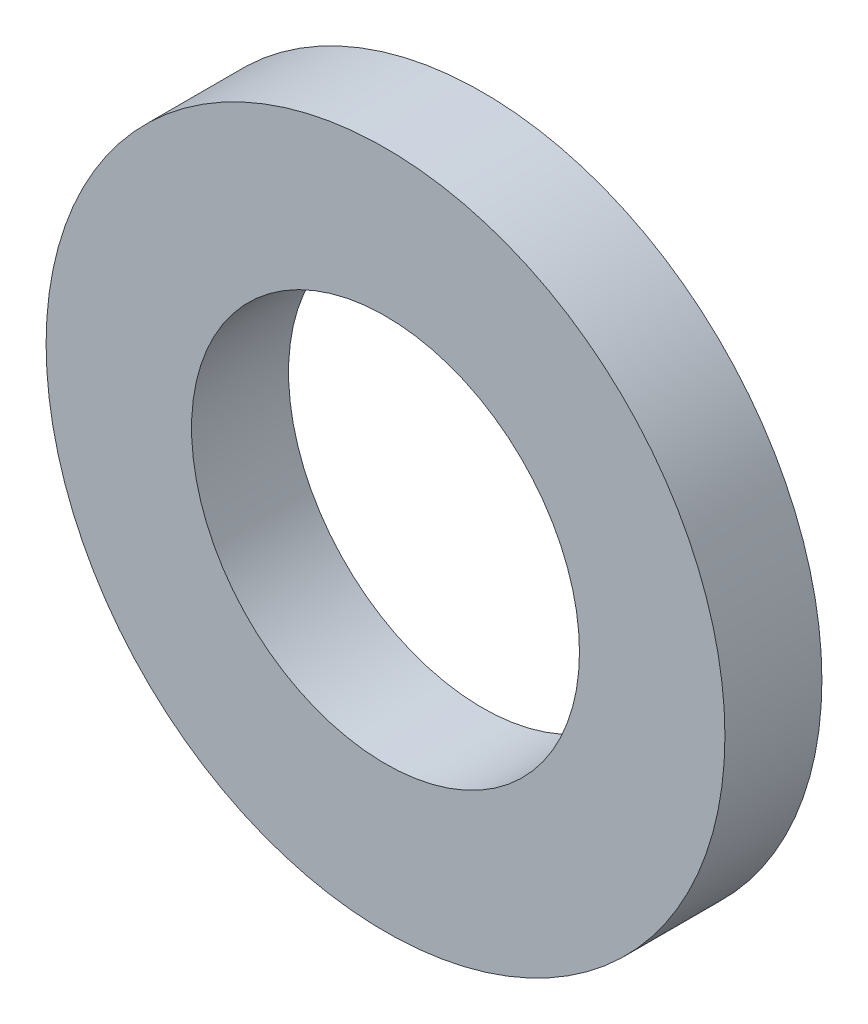
from build123d import *

# Parameters (mm, degrees)
SKETCH1_R           = 7
SKETCH1_R_2         = 4
BOSS_EXTRUDE1_DEPTH = 2


with BuildPart() as part:
    # Sketch1 → Boss-Extrude1 (new body)
    with BuildSketch(Plane.XY):
        Circle(SKETCH1_R)
        Circle(SKETCH1_R_2, mode=Mode.SUBTRACT)
    extrude(amount=BOSS_EXTRUDE1_DEPTH)


solid = part.part
